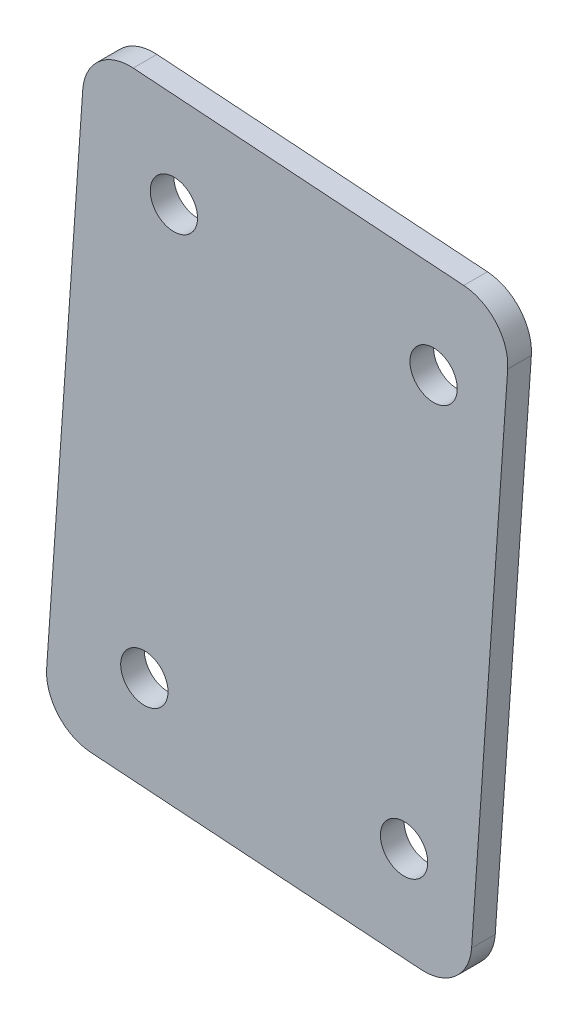
from build123d import *

# Parameters (mm, degrees)
SKETCH1_R           = 3.175
BOSS_EXTRUDE1_DEPTH = 3.175
FILLET1_R           = 6.35


with BuildPart() as part:
    # Sketch1 → Boss-Extrude1 (new body)
    with BuildSketch(Plane.XY):
        Polygon((-353.401390066, 345.241574638), (-296.388854277, 341.280102322), (-302.110980955, 258.928661738), (-359.123516744, 262.890134053), align=None)
        with Locations((-306.771270757, 329.270895311)):
            Circle(SKETCH1_R, mode=Mode.SUBTRACT)
        with Locations((-341.61226485, 331.691795059)):
            Circle(SKETCH1_R, mode=Mode.SUBTRACT)
        with Locations((-345.573737165, 274.67925927)):
            Circle(SKETCH1_R, mode=Mode.SUBTRACT)
        with Locations((-310.732743072, 272.258359522)):
            Circle(SKETCH1_R, mode=Mode.SUBTRACT)
    extrude(amount=BOSS_EXTRUDE1_DEPTH)

    # Fillet1
    fillet1_edges = [part.edges().sort_by_distance(p)[0] for p in [
        (-353.401390066, 345.241574638, 1.5875),
        (-296.388854277, 341.280102322, 1.5875),
        (-302.110980955, 258.928661738, 1.5875),
        (-359.123516744, 262.890134053, 1.5875),
    ]]
    fillet(fillet1_edges, radius=FILLET1_R)


solid = part.part
